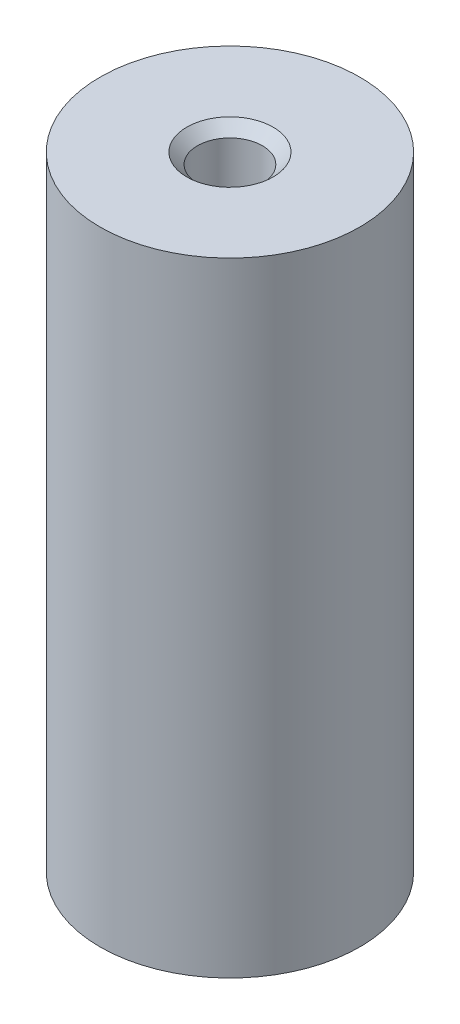
from build123d import *

# Parameters (mm, degrees)
SKETCH_1_R                   = 10
EXTRUDE_1_DEPTH              = 48
HOLE_WIZARD_M6_1_D           = 5
HOLE_WIZARD_M6_1_DEPTH       = 17
HOLE_WIZARD_M6_1_CSINK_D     = 6.65
HOLE_WIZARD_M6_1_CSINK_ANGLE = 90
HOLE_WIZARD_M6_1_TIP         = 1.502151548


with BuildPart() as part:
    # 草图1 → 凸台-拉伸1 (new body)
    with BuildSketch(Plane(origin=(0, 0, 0), x_dir=(1, 0, 0), z_dir=(0, 1, 0))):
        Circle(SKETCH_1_R)
    extrude(amount=EXTRUDE_1_DEPTH)

    # M6 螺纹孔1
    with Locations(Plane.ZX.offset(48)):
        with Locations((0, 0)):
            CounterSinkHole(HOLE_WIZARD_M6_1_D / 2, HOLE_WIZARD_M6_1_CSINK_D / 2, depth=HOLE_WIZARD_M6_1_DEPTH, counter_sink_angle=HOLE_WIZARD_M6_1_CSINK_ANGLE)
            with Locations((0, 0, -(HOLE_WIZARD_M6_1_DEPTH + HOLE_WIZARD_M6_1_TIP / 2))):  # 118° drill point
                Cone(0, HOLE_WIZARD_M6_1_D / 2, HOLE_WIZARD_M6_1_TIP, mode=Mode.SUBTRACT)


solid = part.part
